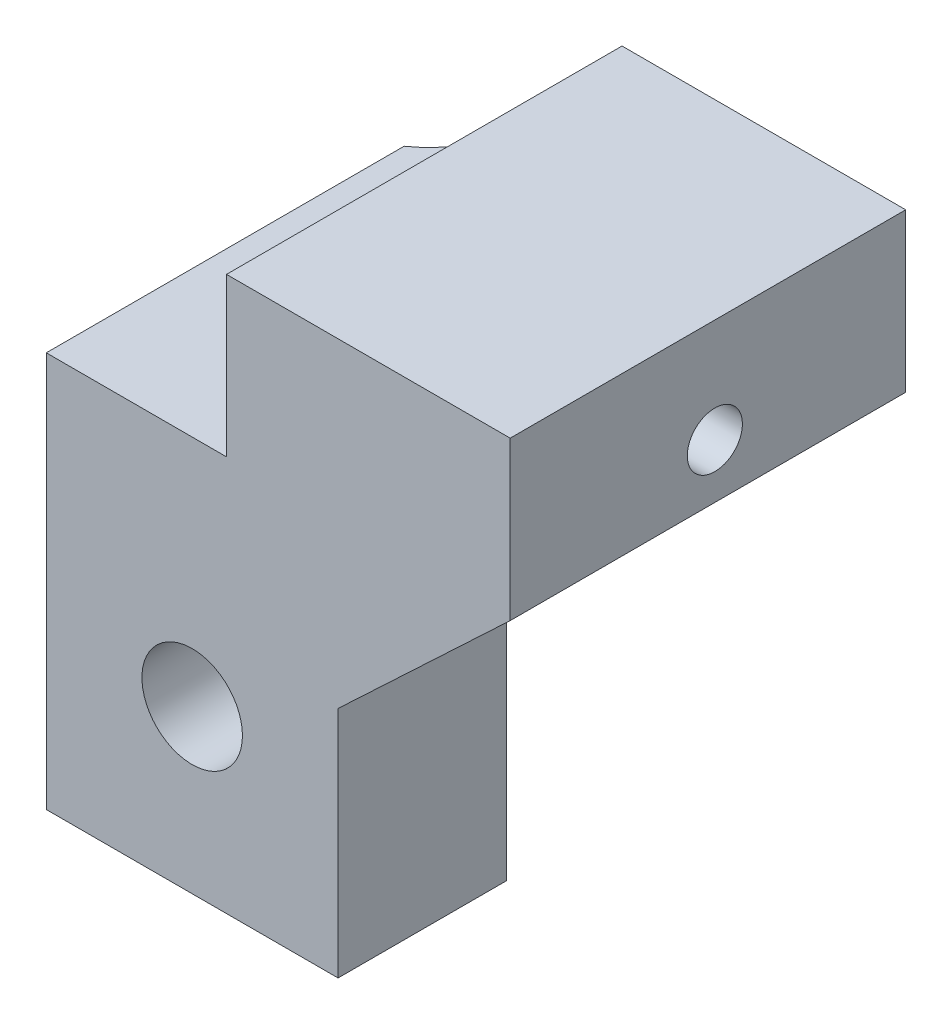
from build123d import *

# Parameters (mm, degrees)
BOSS_EXTRUDE1_DEPTH     = 12.2
SKETCH3_R               = 0.85
CUT_EXTRUDE1_DEPTH      = 8.75
CUT_EXTRUDE2_REACH      = 14.2
SKETCH4_R               = 1.55
SKETCH5_R               = 1.55
CUT_EXTRUDE3_DEPTH      = 1
CUT_EXTRUDE3_DEPTH_BACK = 7


with BuildPart() as part:
    # Sketch2 → Boss-Extrude1 (new body)
    with BuildSketch(Plane.XY.offset(-44.970352008)):
        Polygon((-11.212990891, 70.521798878), (-11.212990891, 58.321361968), (-2.212990891, 58.321361968), (-2.212990891, 65.521798878), (3.096001096, 70.521798878), (3.096001096, 75.396798878), (-5.653998904, 75.396798878), (-5.653998904, 70.521798878), align=None)
    extrude(amount=-BOSS_EXTRUDE1_DEPTH)

    # Sketch3 → Cut-Extrude1 (cut)
    with BuildSketch(Plane.ZY.offset(5.653998904)):
        with Locations((-51.282859951, 72.195892432)):
            Circle(SKETCH3_R)
    extrude(amount=-CUT_EXTRUDE1_DEPTH, mode=Mode.SUBTRACT)

    # Sketch4 → Cut-Extrude2 (cut, up to next)
    with BuildSketch(Plane.XY.offset(-44.970352008), mode=Mode.PRIVATE) as cut_extrude2_sk1:
        with Locations((-6.712990891, 63.321361968)):
            Circle(SKETCH4_R)
    cut_extrude2_tool1 = extrude(cut_extrude2_sk1.sketch, amount=-CUT_EXTRUDE2_REACH, mode=Mode.PRIVATE) & part.part
    add(cut_extrude2_tool1.solids().sort_by_distance((-6.712991, 63.321362, -44.970352))[0], mode=Mode.SUBTRACT)

    # Sketch5 → Cut-Extrude3 (cut, two sides)
    with BuildSketch(Plane(origin=(0, 0, -57.170352008), x_dir=(-1, 0, 0), z_dir=(0, 0, -1))) as cut_extrude3_sk:
        Polygon((11.212990891, 66.612258502), (1.05514261, 66.612258502), (2.212990891, 65.521798878), (2.212990891, 58.321361968), (11.212990891, 58.321361968), align=None)
        with Locations((6.712990891, 63.321361968)):
            Circle(SKETCH5_R, mode=Mode.SUBTRACT)
    extrude(amount=CUT_EXTRUDE3_DEPTH, mode=Mode.SUBTRACT)
    extrude(cut_extrude3_sk.sketch, amount=-CUT_EXTRUDE3_DEPTH_BACK, mode=Mode.SUBTRACT)

    # Sketch7 → Cut-Revolve1 (revolve, cut)
    with BuildSketch(Plane(origin=(0, 0, -58.682859951), x_dir=(-1, 0, 0), z_dir=(0, 0, -1))):
        Polygon((11.212990891, 66.612258502), (11.212990891, 70.521798878), (9.823409812, 70.521798878), (9.273959744, 66.612258502), align=None)
    revolve(axis=Axis((-13.092990891, 78.216716655, -58.682859951), (0, -1, 0)), mode=Mode.SUBTRACT)


solid = part.part
